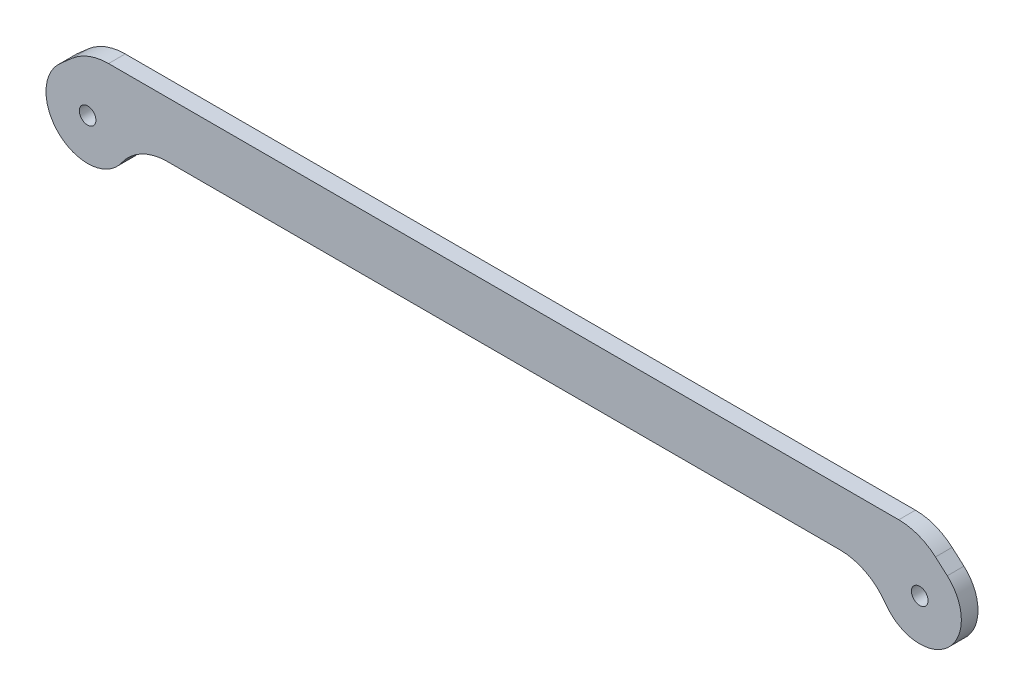
from build123d import *

# Parameters (mm, degrees)
SKETCH1_R           = 1.5
BOSS_EXTRUDE1_DEPTH = 3
FILLET1_R           = 10


with BuildPart() as part:
    # Sketch1 → Boss-Extrude1 (new body)
    with BuildSketch(Plane.XY):
        with BuildLine():
            Line((0, 10), (-4.960783708, 5.625))
            ThreePointArc((-4.960783708, 5.625), (-3.085783708, -6.835783708), (7.5, 0))
            Line((7.5, 0), (142.5, 0))
            ThreePointArc((142.5, 0), (153.085783708, -6.835783708), (154.960783708, 5.625))
            Line((154.960783708, 5.625), (150, 10))
            Line((150, 10), (0, 10))
        make_face()
        Circle(SKETCH1_R, mode=Mode.SUBTRACT)
        with Locations((150, 0)):
            Circle(SKETCH1_R, mode=Mode.SUBTRACT)
    extrude(amount=BOSS_EXTRUDE1_DEPTH)

    # Fillet1
    fillet1_edges = [part.edges().sort_by_distance(p)[0] for p in [
        (7.5, 0, 1.5),
        (0, 10, 1.5),
        (150, 10, 1.5),
        (142.5, 0, 1.5),
    ]]
    fillet(fillet1_edges, radius=FILLET1_R)


solid = part.part
